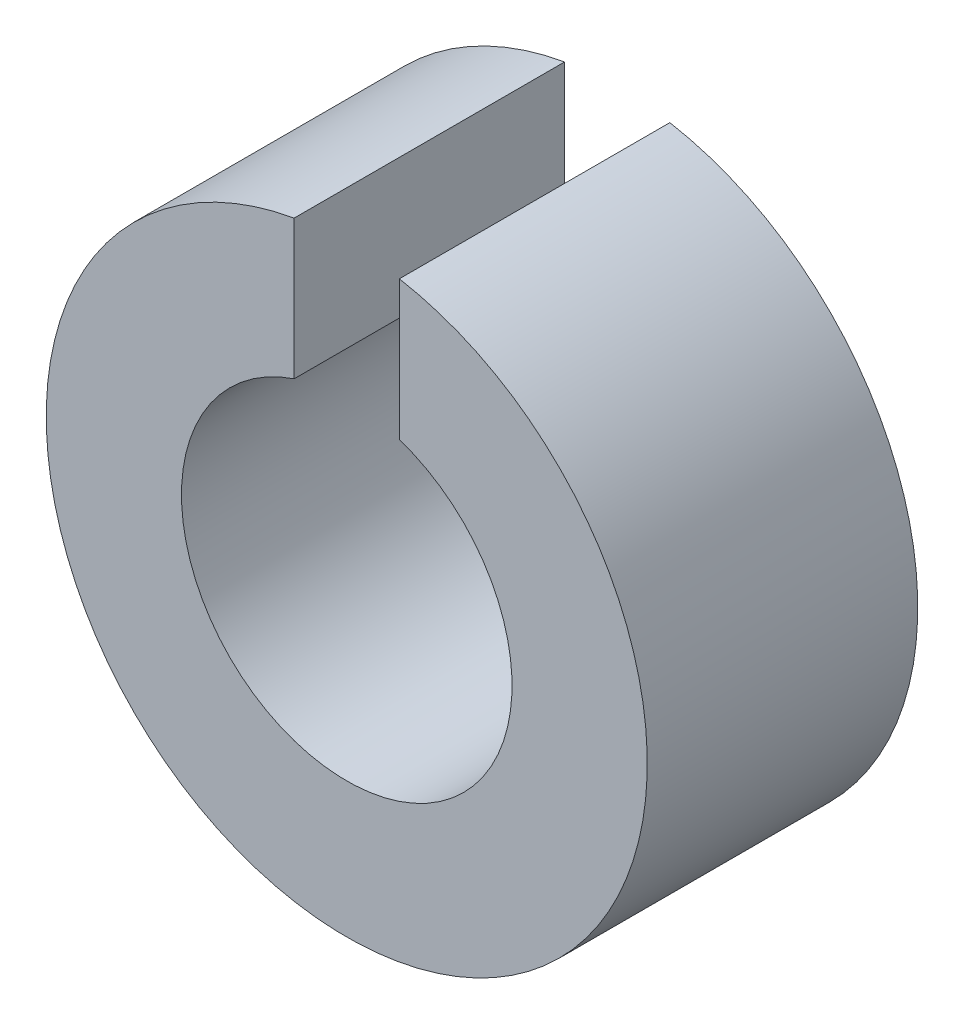
from build123d import *

# Parameters (mm, degrees)
SKETCH_1_R          = 10
SKETCH_1_R_2        = 5.5
EXTRUDE_1_DEPTH     = 9
SKETCH_2_W          = 3.5
SKETCH_2_H          = 15
CUT_EXTRUDE_1_DEPTH = 10


with BuildPart() as part:
    # Эскиз1 → Бобышка-Вытянуть1 (new body)
    with BuildSketch(Plane.XY):
        Circle(SKETCH_1_R)
        Circle(SKETCH_1_R_2, mode=Mode.SUBTRACT)
    extrude(amount=EXTRUDE_1_DEPTH)

    # Эскиз2 → Вырез-Вытянуть1 (cut, through all)
    with BuildSketch(Plane.XY.offset(9)):
        with Locations((0, 10)):
            Rectangle(SKETCH_2_W, SKETCH_2_H)
    extrude(amount=-CUT_EXTRUDE_1_DEPTH, mode=Mode.SUBTRACT)


solid = part.part
